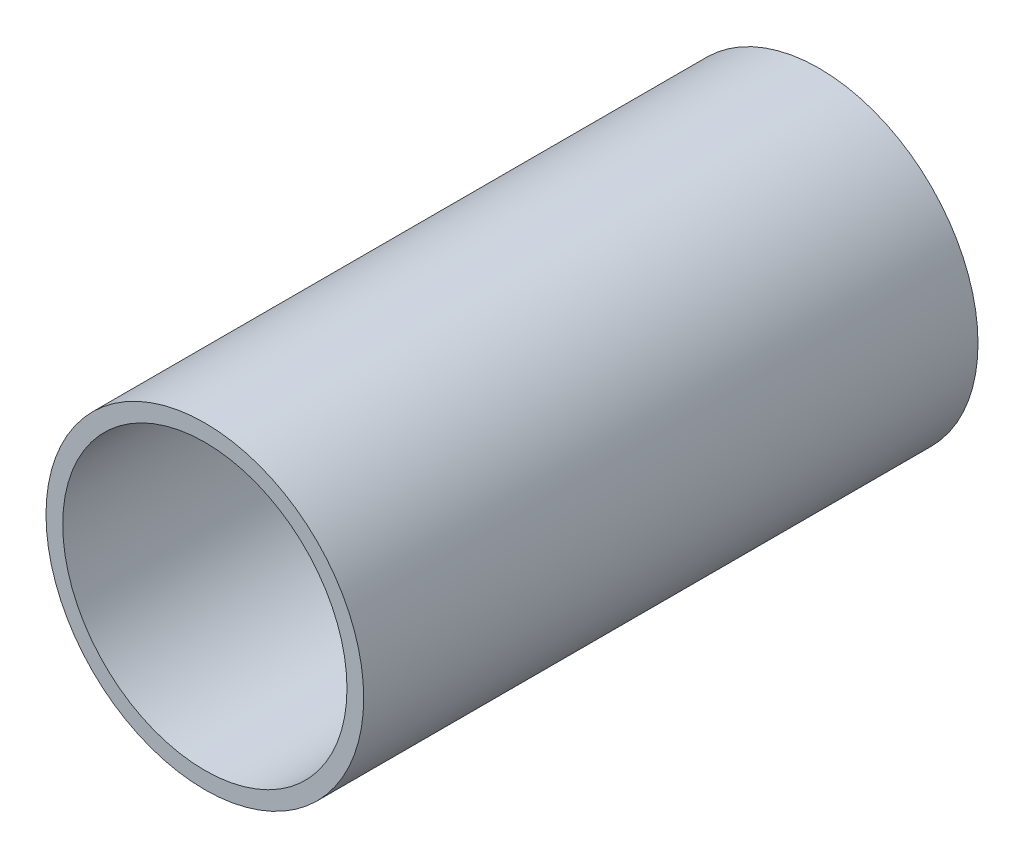
from build123d import *

# Parameters (mm, degrees)
SKETCH1_R           = 57.15
SKETCH1_R_2         = 51.1302
EXTRUDE_THIN1_DEPTH = 110.5


with BuildPart() as part:
    # Sketch1 → Extrude-Thin1 (new body, symmetric)
    with BuildSketch(Plane.XY):
        Circle(SKETCH1_R)
        Circle(SKETCH1_R_2, mode=Mode.SUBTRACT)
    extrude(amount=EXTRUDE_THIN1_DEPTH, both=True)


solid = part.part
